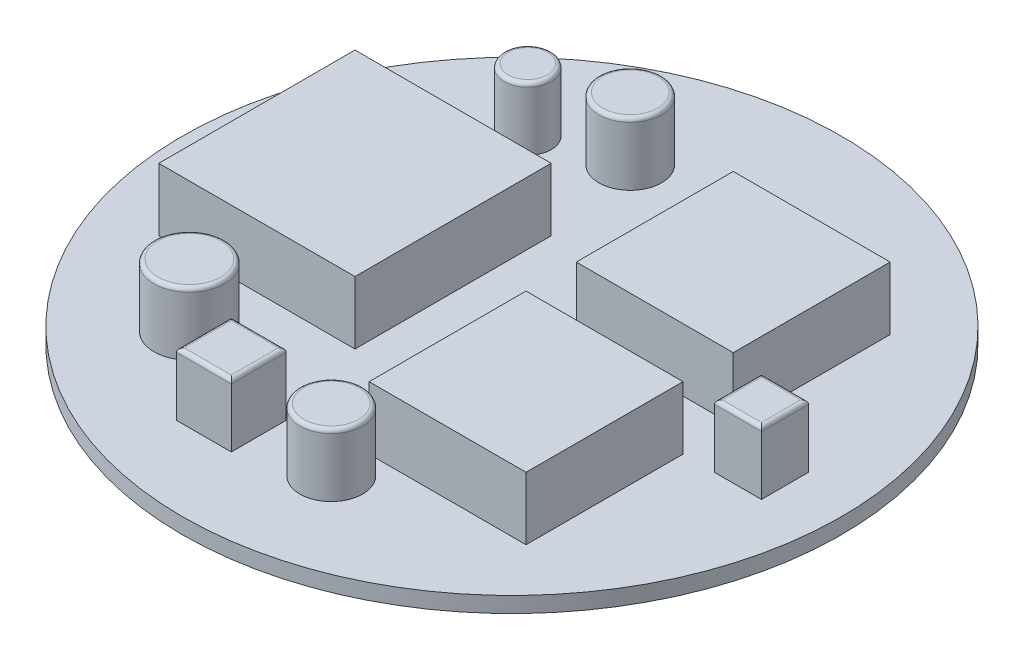
from build123d import *

# Parameters (mm, degrees)
SKETCH1_R           = 42
BOSS_EXTRUDE1_DEPTH = 2
SKETCH2_R           = 3
SKETCH2_R_2         = 4
SKETCH2_R_3         = 4.5
SKETCH2_W           = 25
SKETCH2_H           = 25
SKETCH2_W_2         = 20
SKETCH2_H_2         = 20
SKETCH2_W_3         = 7
SKETCH2_H_3         = 7
SKETCH2_W_4         = 6
SKETCH2_H_4         = 6
BOSS_EXTRUDE2_DEPTH = 8
FILLET1_R           = 0.5


with BuildPart() as part:
    # Sketch1 → Boss-Extrude1 (new body)
    with BuildSketch(Plane(origin=(0, 0, 0), x_dir=(1, 0, 0), z_dir=(0, 1, 0))):
        Circle(SKETCH1_R)
    extrude(amount=BOSS_EXTRUDE1_DEPTH)

    # Sketch2 → Boss-Extrude2 (add)
    with BuildSketch(Plane(origin=(0, 2, 0), x_dir=(1, 0, 0), z_dir=(0, 1, 0))):
        with Locations((-20, 22.020171122)):
            Circle(SKETCH2_R)
        with Locations((-10.302496515, 25.377676752)):
            Circle(SKETCH2_R_2)
        with Locations((-20, -21.114457143)):
            Circle(SKETCH2_R_3)
        with Locations((5, -28.020526235)):
            Circle(SKETCH2_R_2)
        with Locations((-20, 0)):
            Rectangle(SKETCH2_W, SKETCH2_H)
        with Locations((15, 13.203564029)):
            Rectangle(SKETCH2_W_2, SKETCH2_H_2)
        with Locations((15, -13.203564029)):
            Rectangle(SKETCH2_W_2, SKETCH2_H_2)
        with Locations((-7.518218001, -28.243397592)):
            Rectangle(SKETCH2_W_3, SKETCH2_H_3)
        with Locations((32.002130678, -0.203564029)):
            Rectangle(SKETCH2_W_4, SKETCH2_H_4)
    extrude(amount=BOSS_EXTRUDE2_DEPTH)

    # Fillet1
    fillet1_edges = [part.edges().sort_by_distance(p)[0] for p in [
        (-23, 10, -22.020171122),
        (-14.302496515, 10, -25.377676752),
        (-24.5, 10, 21.114457143),
        (1, 10, 28.020526235),
        (-11.018218001, 10, 28.243397592),
        (-7.518218001, 10, 31.743397592),
        (-4.018218001, 10, 28.243397592),
        (-7.518218001, 10, 24.743397592),
        (35.002130678, 10, 0.203564029),
        (32.002130678, 10, -2.796435971),
        (29.002130678, 10, 0.203564029),
        (32.002130678, 10, 3.203564029),
    ]]
    fillet(fillet1_edges, radius=FILLET1_R)

    # Sketch6 → Revolve1 (revolve)
    with BuildSketch(Plane(origin=(0, 0, 0), x_dir=(0, 0, -1), z_dir=(1, 0, 0))):
        with BuildLine():
            Line((0, 0), (0, -15.408613296))
            ThreePointArc((0, -15.408613296), (-14.683539795, -11.247032644), (-25, 0))
            Line((-25, 0), (0, 0))
        make_face()
    revolve(axis=Axis((0, 0, 0), (0, -1, 0)))


solid = part.part
